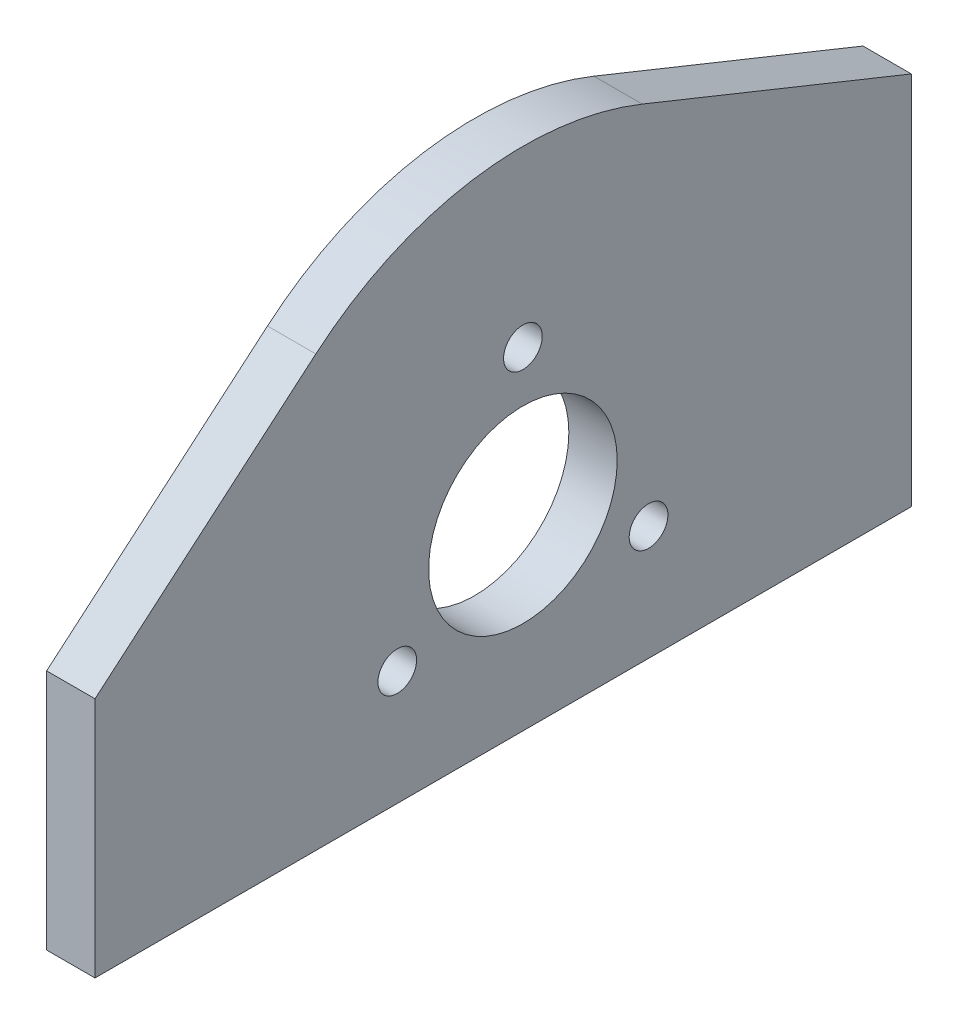
from build123d import *

# Parameters (mm, degrees)
ESTRUSIONE_ESTRUSIONE1_DEPTH = 5
SCHIZZO2_R                   = 4
SCHIZZO2_R_2                 = 2
SCHIZZO2_R_3                 = 9.75
TAGLIO_ESTRUSIONE1_DEPTH     = 6


with BuildPart() as part:
    # Schizzo3 → Estrusione-Estrusione1 (new body)
    with BuildSketch(Plane(origin=(0, 0, 0), x_dir=(0, 0, -1), z_dir=(1, 0, 0))):
        with BuildLine():
            Line((40.160183768, 61.647051924), (40.160183768, 100.394835388))
            Line((40.160183768, 100.394835388), (12.334616938, 111.608123513))
            ThreePointArc((12.334616938, 111.608123513), (-5.305430843, 113.570729245), (-21.410737295, 106.111358555))
            Line((-21.410737295, 106.111358555), (-44.239245072, 86.647051924))
            Line((-44.239245072, 86.647051924), (-44.239245072, 61.647051924))
            Line((-44.239245072, 61.647051924), (40.160183768, 61.647051924))
        make_face()
    extrude(amount=ESTRUSIONE_ESTRUSIONE1_DEPTH)

    # Schizzo2 → Taglio-Estrusione1 (cut, through all)
    with BuildSketch(Plane(origin=(0, 0, 0), x_dir=(0, 0, -1), z_dir=(1, 0, 0))):
        with Locations((-95, 0)):
            Circle(SCHIZZO2_R)
        with Locations((201, 0)):
            Circle(SCHIZZO2_R)
        with Locations((12.990381057, 73.5)):
            Circle(SCHIZZO2_R_2)
        with Locations((-12.990381057, 73.5)):
            Circle(SCHIZZO2_R_2)
        with Locations((0, 96)):
            Circle(SCHIZZO2_R_2)
        with Locations((0, 81)):
            Circle(SCHIZZO2_R_3)
    extrude(amount=TAGLIO_ESTRUSIONE1_DEPTH, mode=Mode.SUBTRACT)


solid = part.part
